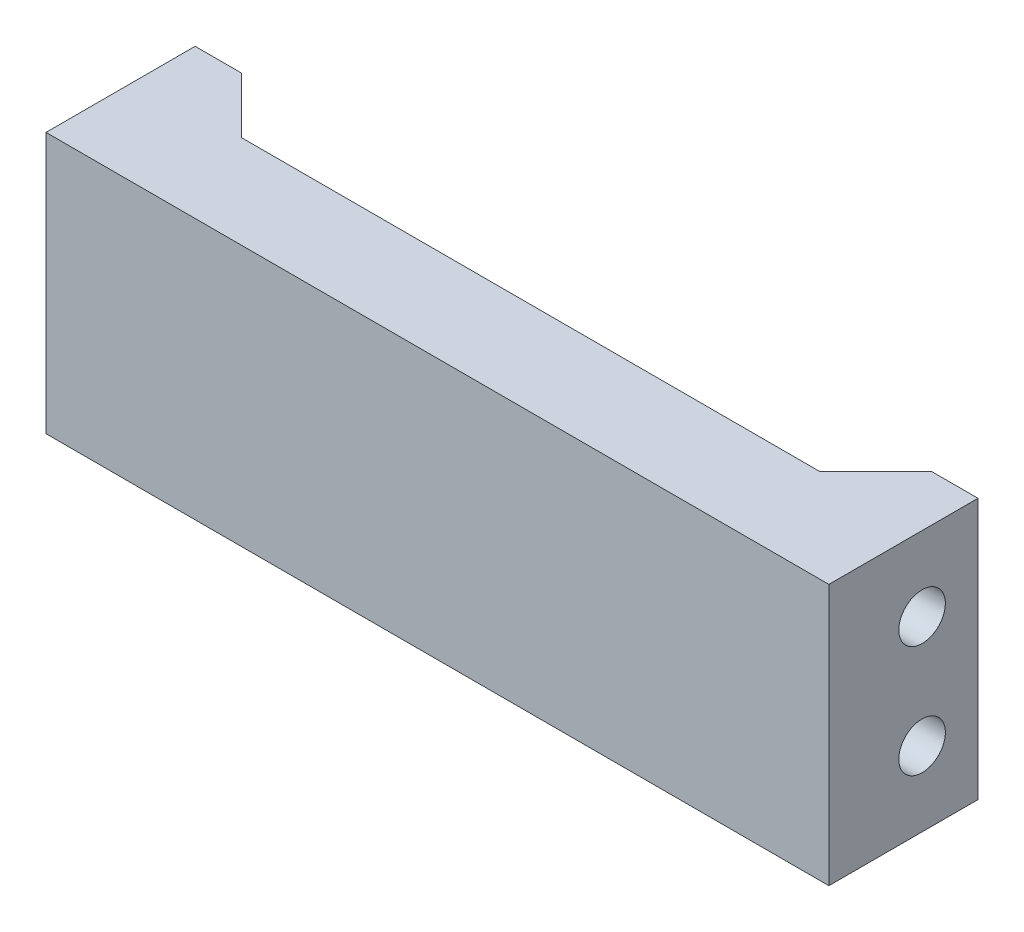
from build123d import *

# Parameters (mm, degrees)
SKETCH1_W           = 42
SKETCH1_H           = 14
BOSS_EXTRUDE1_DEPTH = 2
SKETCH2_W           = 2.5
SKETCH2_H           = 14
BOSS_EXTRUDE2_DEPTH = 6
SKETCH5_R           = 1.25
CUT_EXTRUDE1_DEPTH  = 43
BOSS_EXTRUDE3_DEPTH = 2


with BuildPart() as part:
    # Sketch1 → Boss-Extrude1 (new body)
    with BuildSketch(Plane.XY):
        Rectangle(SKETCH1_W, SKETCH1_H)
    extrude(amount=BOSS_EXTRUDE1_DEPTH)

    # Sketch2 → Boss-Extrude2 (add)
    with BuildSketch(Plane(origin=(0, 0, 0), x_dir=(-1, 0, 0), z_dir=(0, 0, -1))):
        with Locations((-19.75, 0)):
            Rectangle(SKETCH2_W, SKETCH2_H)
        with Locations((19.75, 0)):
            Rectangle(SKETCH2_W, SKETCH2_H)
    extrude(amount=BOSS_EXTRUDE2_DEPTH)

    # Sketch5 → Cut-Extrude1 (cut, through all)
    with BuildSketch(Plane(origin=(21, 0, 0), x_dir=(0, 0, -1), z_dir=(1, 0, 0))):
        with Locations((3, 3)):
            Circle(SKETCH5_R)
        with Locations((3, -3)):
            Circle(SKETCH5_R)
    extrude(amount=-CUT_EXTRUDE1_DEPTH, mode=Mode.SUBTRACT)

    # Sketch6 → Boss-Extrude3 (add)
    with BuildSketch(Plane(origin=(0, 7, 0), x_dir=(1, 0, 0), z_dir=(0, 1, 0))):
        Polygon((-18.5, 6), (-18.5, 0), (-12.5, 0), (12.5, 0), (18.5, 0), (18.5, 6), (15.5, 3), (-15.5, 3), align=None)
    boss_extrude3 = extrude(amount=-BOSS_EXTRUDE3_DEPTH)

    # Mirror1: Boss-Extrude3 across plane
    add(boss_extrude3.mirror(Plane.ZX))


solid = part.part
